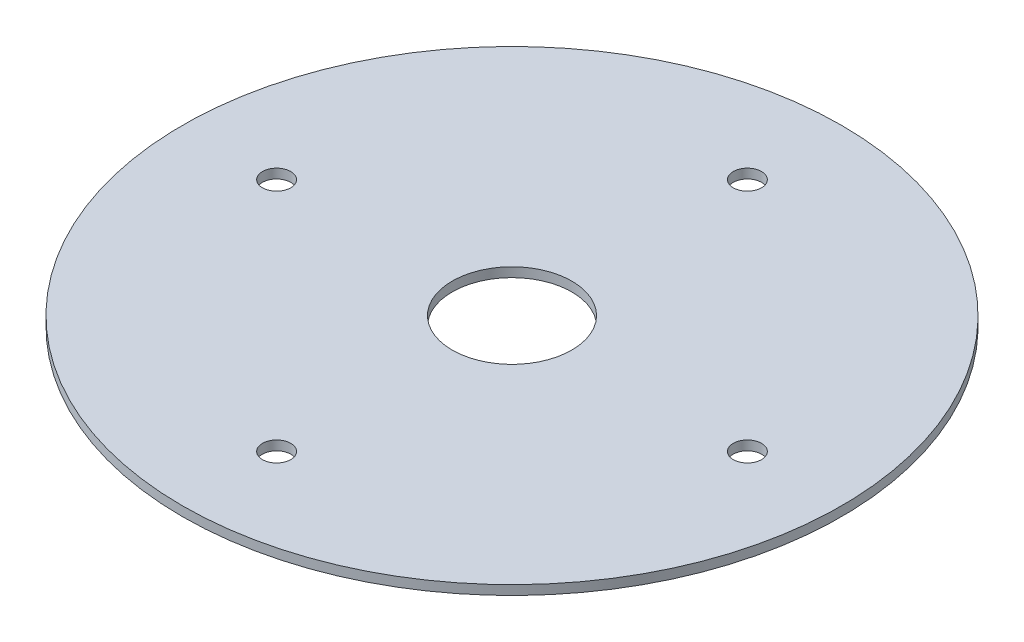
from build123d import *

# Parameters (mm, degrees)
SKETCH1_R           = 35
BOSS_EXTRUDE1_DEPTH = 1
SKETCH2_R           = 6.35
CUT_EXTRUDE1_DEPTH  = 1
SKETCH3_R           = 1.5
CUT_EXTRUDE4_DEPTH  = 1
CIRPATTERN1_COUNT   = 4


with BuildPart() as part:
    # Sketch1 → Boss-Extrude1 (new body)
    with BuildSketch(Plane(origin=(0, 0, 0), x_dir=(1, 0, 0), z_dir=(0, 1, 0))):
        Circle(SKETCH1_R)
    extrude(amount=BOSS_EXTRUDE1_DEPTH)

    # Sketch2 → Cut-Extrude1 (cut)
    with BuildSketch(Plane(origin=(0, 1, 0), x_dir=(1, 0, 0), z_dir=(0, 1, 0))):
        Circle(SKETCH2_R)
    extrude(amount=-CUT_EXTRUDE1_DEPTH, mode=Mode.SUBTRACT)

    # Sketch3 → Cut-Extrude4 (cut)
    with BuildSketch(Plane(origin=(0, 1, 0), x_dir=(1, 0, 0), z_dir=(0, 1, 0))):
        with Locations((0, 25)):
            Circle(SKETCH3_R)
    cut_extrude4 = extrude(amount=-CUT_EXTRUDE4_DEPTH, mode=Mode.SUBTRACT)

    # CirPattern1: Cut-Extrude4 ×4 about axis
    cirpattern1_axis = Axis((0, 1.05, 0), (0, -1, 0))
    for i in range(1, CIRPATTERN1_COUNT):
        add(cut_extrude4.rotate(cirpattern1_axis, i * 360 / CIRPATTERN1_COUNT), mode=Mode.SUBTRACT)


solid = part.part
